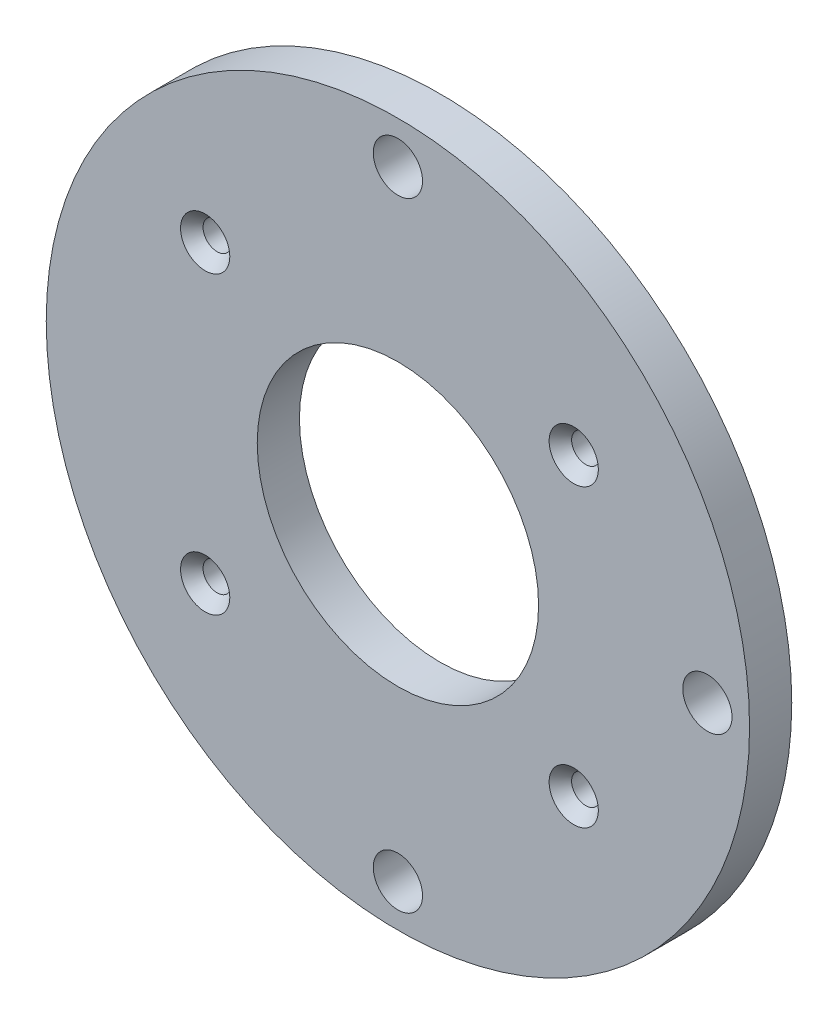
from build123d import *

# Parameters (mm, degrees)
SKETCH_1_W          = 25
SKETCH_1_H          = 3
HOLE_WIZARD_1_D     = 2.013
HOLE_WIZARD_2_D     = 2.013
HOLE_WIZARD_2_DEPTH = 3
HOLE_WIZARD_3_D     = 2.013
HOLE_WIZARD_3_DEPTH = 3
HOLE_WIZARD_4_D     = 2.013
HOLE_WIZARD_4_DEPTH = 3
HOLE_WIZARD_5_D     = 3.5
HOLE_WIZARD_5_DEPTH = 3
HOLE_WIZARD_6_D     = 3.5
HOLE_WIZARD_6_DEPTH = 3
HOLE_WIZARD_7_D     = 20
HOLE_WIZARD_7_DEPTH = 3
HOLE_WIZARD_8_D     = 3.5
HOLE_WIZARD_8_DEPTH = 3
CHAMFER_1_SIZE      = 0.7435
CHAMFER_1_SIZE2     = 0.855298911
CHAMFER_2_SIZE      = 0.7435
CHAMFER_2_SIZE2     = 0.855298911
CHAMFER_3_SIZE      = 0.7435
CHAMFER_3_SIZE2     = 0.855298911
CHAMFER_4_SIZE      = 0.7435
CHAMFER_4_SIZE2     = 0.855298911


with BuildPart() as part:
    # Эскиз1 → Повернуть1 (revolve)
    with BuildSketch(Plane(origin=(0, 0, 0), x_dir=(1, 0, 0), z_dir=(0, 1, 0))):
        with Locations((12.5, -1.5)):
            Rectangle(SKETCH_1_W, SKETCH_1_H)
    revolve(axis=Axis((0, 0, 0), (0, 0, 1)))

    # Отверстие1 (through all)
    with Locations(Plane.XY.offset(3)):
        with Locations((-13.7, -10.5)):
            Hole(HOLE_WIZARD_1_D / 2)

    # Отверстие2
    with Locations(Plane.XY.offset(3)):
        with Locations((12.5, 10.5)):
            Hole(HOLE_WIZARD_2_D / 2, depth=HOLE_WIZARD_2_DEPTH)

    # Отверстие3
    with Locations(Plane.XY.offset(3)):
        with Locations((-13.7, 10.5)):
            Hole(HOLE_WIZARD_3_D / 2, depth=HOLE_WIZARD_3_DEPTH)

    # Отверстие4
    with Locations(Plane.XY.offset(3)):
        with Locations((12.5, -10.5)):
            Hole(HOLE_WIZARD_4_D / 2, depth=HOLE_WIZARD_4_DEPTH)

    # Отверстие5
    with Locations(Plane.XY.offset(3)):
        with Locations((0, -22)):
            Hole(HOLE_WIZARD_5_D / 2, depth=HOLE_WIZARD_5_DEPTH)

    # Отверстие6
    with Locations(Plane.XY.offset(3)):
        with Locations((0, 22)):
            Hole(HOLE_WIZARD_6_D / 2, depth=HOLE_WIZARD_6_DEPTH)

    # Отверстие7
    with Locations(Plane.XY.offset(3)):
        with Locations((0, 0)):
            Hole(HOLE_WIZARD_7_D / 2, depth=HOLE_WIZARD_7_DEPTH)

    # Отверстие8
    with Locations(Plane.XY.offset(3)):
        with Locations((22, 0)):
            Hole(HOLE_WIZARD_8_D / 2, depth=HOLE_WIZARD_8_DEPTH)

    # Фаска1
    chamfer_1_edges = [part.edges().sort_by_distance(p)[0] for p in [
        (-12.6935, 10.5, 3),
    ]]
    chamfer_1_side = [part.faces().sort_by_distance(p)[0] for p in [
        (-24.292893219, 0, 3),
    ]]
    chamfer(chamfer_1_edges, length=CHAMFER_1_SIZE, length2=CHAMFER_1_SIZE2, reference=chamfer_1_side[0])

    # Фаска2
    chamfer_2_edges = [part.edges().sort_by_distance(p)[0] for p in [
        (13.5065, -10.5, 3),
    ]]
    chamfer_2_side = [part.faces().sort_by_distance(p)[0] for p in [
        (-11.242893219, 10.5, 3),
    ]]
    chamfer(chamfer_2_edges, length=CHAMFER_2_SIZE, length2=CHAMFER_2_SIZE2, reference=chamfer_2_side[0])

    # Фаска3
    chamfer_3_edges = [part.edges().sort_by_distance(p)[0] for p in [
        (13.5065, 10.5, 3),
    ]]
    chamfer_3_side = [part.faces().sort_by_distance(p)[0] for p in [
        (14.957106781, -10.5, 3),
    ]]
    chamfer(chamfer_3_edges, length=CHAMFER_3_SIZE, length2=CHAMFER_3_SIZE2, reference=chamfer_3_side[0])

    # Фаска4
    chamfer_4_edges = [part.edges().sort_by_distance(p)[0] for p in [
        (-12.6935, -10.5, 3),
    ]]
    chamfer_4_side = [part.faces().sort_by_distance(p)[0] for p in [
        (14.957106781, 10.5, 3),
    ]]
    chamfer(chamfer_4_edges, length=CHAMFER_4_SIZE, length2=CHAMFER_4_SIZE2, reference=chamfer_4_side[0])


solid = part.part
